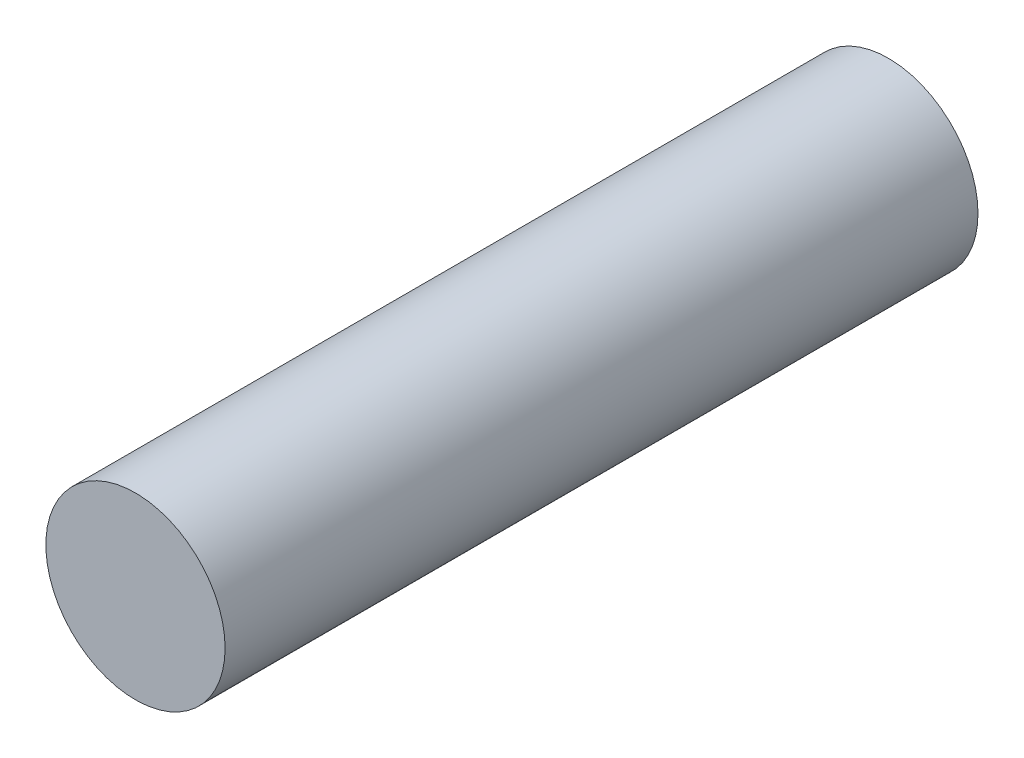
from build123d import *

# Parameters (mm, degrees)
ESQUISSE1_R          = 0.5
BASE_EXTRUSION_DEPTH = 2.1


with BuildPart() as part:
    # Esquisse1 → Base-Extrusion (new body, symmetric)
    with BuildSketch(Plane.XY):
        Circle(ESQUISSE1_R)
    extrude(amount=BASE_EXTRUSION_DEPTH, both=True)


solid = part.part
